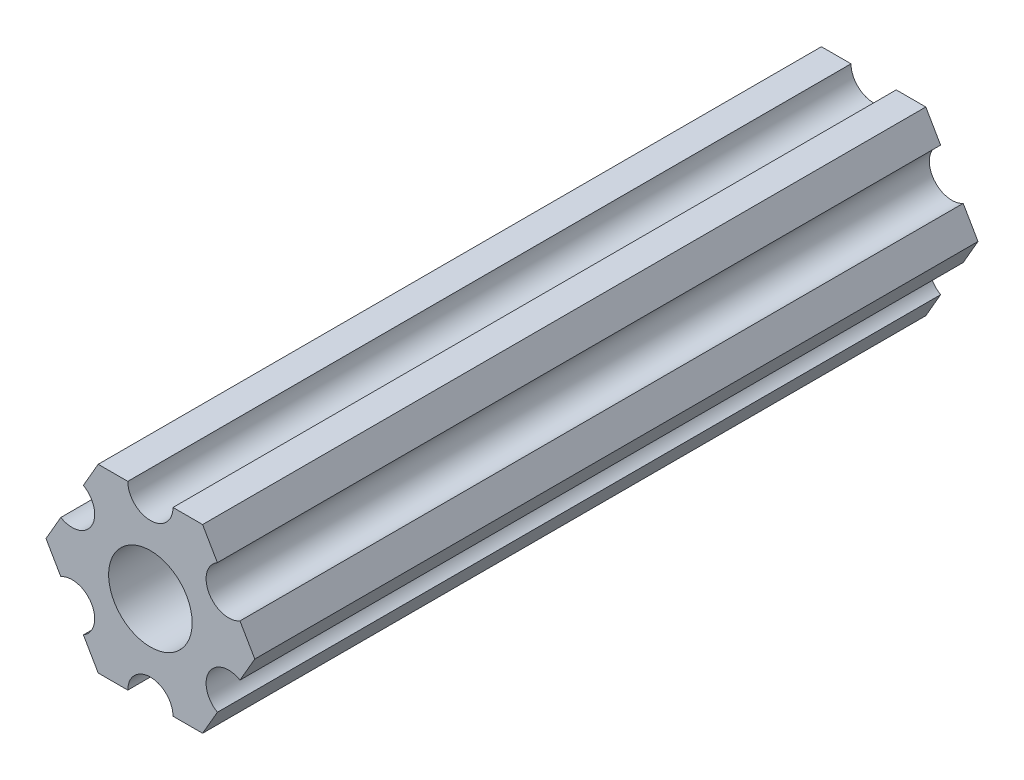
from build123d import *

# Parameters (mm, degrees)
SKETCH1_R           = 2.9337
BOSS_EXTRUDE1_DEPTH = 50.8


with BuildPart() as part:
    # Sketch1 → Boss-Extrude1 (new body)
    with BuildSketch(Plane(origin=(0, 0, 0), x_dir=(-1, 0, 0), z_dir=(0, 0, -1))):
        with BuildLine():
            Line((-4.70551159, -4.549815043), (-3.666174521, -6.349999904))
            Line((-3.666174521, -6.349999904), (-1.587500385, -6.349999904))
            ThreePointArc((-1.587500385, -6.349999904), (-3.85e-07, -4.762499904), (1.587499615, -6.349999904))
            Line((1.587499615, -6.349999904), (3.666173825, -6.349999904))
            Line((3.666173825, -6.349999904), (4.705510942, -4.54981524))
            ThreePointArc((4.705510942, -4.54981524), (4.124445629, -2.381249907), (6.293010962, -1.800184594))
            Line((6.293010962, -1.800184594), (7.332348079, 7e-08))
            Line((7.332348079, 7e-08), (6.293011217, 1.800184685))
            ThreePointArc((6.293011217, 1.800184685), (4.124445939, 2.381250203), (4.705511457, 4.549815481))
            Line((4.705511457, 4.549815481), (3.666174521, 6.350000222))
            Line((3.666174521, 6.350000222), (1.587500385, 6.350000222))
            ThreePointArc((1.587500385, 6.350000222), (3.85e-07, 4.762500222), (-1.587499615, 6.350000222))
            Line((-1.587499615, 6.350000222), (-3.666173825, 6.350000222))
            Line((-3.666173825, 6.350000222), (-4.705511038, 4.549815614))
            ThreePointArc((-4.705511038, 4.549815614), (-4.124445841, 2.38125025), (-6.293011205, 1.800185053))
            Line((-6.293011205, 1.800185053), (-7.332348419, 4.44e-07))
            Line((-7.332348419, 4.44e-07), (-6.293011423, -1.80018429))
            ThreePointArc((-6.293011423, -1.80018429), (-4.12444613, -2.38124975), (-4.70551159, -4.549815043))
        make_face()
        Circle(SKETCH1_R, mode=Mode.SUBTRACT)
    extrude(amount=BOSS_EXTRUDE1_DEPTH)


solid = part.part
